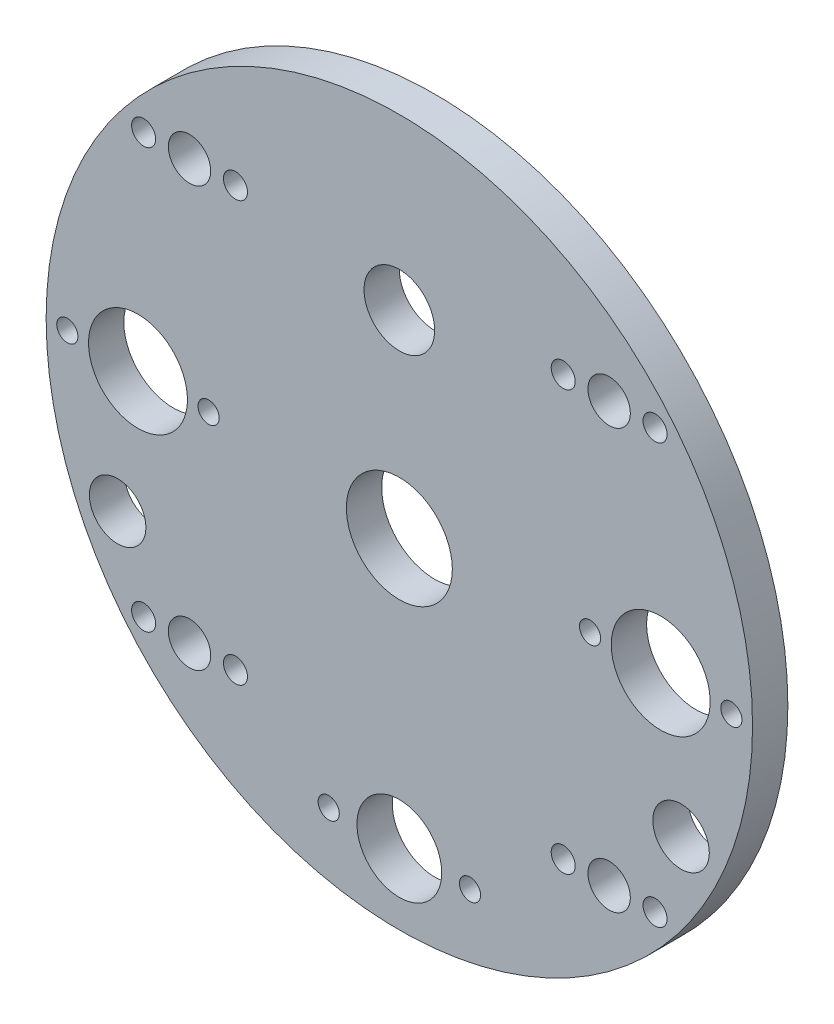
from build123d import *

# Parameters (mm, degrees)
SKETCH1_R                  = 50
BOSS_EXTRUDE1_DEPTH        = 5
F_14_0_14_DIAMETER_HOLE1_D = 14
SKETCH7_R                  = 5
CUT_EXTRUDE1_DEPTH         = 10
SKETCH8_R                  = 3
CUT_EXTRUDE2_DEPTH         = 10
CIRPATTERN1_COUNT          = 4
SKETCH9_R                  = 7.5
CUT_EXTRUDE3_DEPTH         = 10
SKETCH10_R                 = 1.5
SKETCH10_R_2               = 6
CUT_EXTRUDE4_DEPTH         = 10
SKETCH12_R                 = 4
CUT_EXTRUDE5_DEPTH         = 10
M3_CLEARANCE_HOLE1_D       = 3.4
MIRROR3_COPY_1_D           = 3.4


with BuildPart() as part:
    # Sketch1 → Boss-Extrude1 (new body)
    with BuildSketch(Plane.XY):
        Circle(SKETCH1_R)
    extrude(amount=BOSS_EXTRUDE1_DEPTH)

    # Ø14.0 (14) Diameter Hole1 (through all)
    with Locations(Plane(origin=(0, 0, 0), x_dir=(-1, 0, 0), z_dir=(0, 0, -1))):
        with Locations((37, 0), (-37, 0)):
            Hole(F_14_0_14_DIAMETER_HOLE1_D / 2)

    # Sketch7 → Cut-Extrude1 (cut)
    with BuildSketch(Plane.XY.offset(5)):
        with Locations((0, 26)):
            Circle(SKETCH7_R)
    extrude(amount=-CUT_EXTRUDE1_DEPTH, mode=Mode.SUBTRACT)

    # Sketch8 → Cut-Extrude2 (cut)
    with BuildSketch(Plane.XY.offset(5)):
        with Locations((-29.69848481, 29.69848481)):
            Circle(SKETCH8_R)
    cut_extrude2 = extrude(amount=-CUT_EXTRUDE2_DEPTH, mode=Mode.SUBTRACT)

    # CirPattern1: Cut-Extrude2 ×4 about axis
    cirpattern1_axis = Axis((0, 0, 0), (0, 0, 1))
    for i in range(1, CIRPATTERN1_COUNT):
        add(cut_extrude2.rotate(cirpattern1_axis, i * 360 / CIRPATTERN1_COUNT), mode=Mode.SUBTRACT)

    # Sketch9 → Cut-Extrude3 (cut)
    with BuildSketch(Plane.XY.offset(5)):
        with Locations((0, -2)):
            Circle(SKETCH9_R)
    extrude(amount=-CUT_EXTRUDE3_DEPTH, mode=Mode.SUBTRACT)

    # Sketch10 → Cut-Extrude4 (cut)
    with BuildSketch(Plane.XY.offset(5)):
        with Locations((-47, 0)):
            Circle(SKETCH10_R)
        with Locations((-27, 0)):
            Circle(SKETCH10_R)
        with Locations((27, 0)):
            Circle(SKETCH10_R)
        with Locations((47, 0)):
            Circle(SKETCH10_R)
        with Locations((10, -40)):
            Circle(SKETCH10_R)
        with Locations((-10, -40)):
            Circle(SKETCH10_R)
        with Locations((0, -40)):
            Circle(SKETCH10_R_2)
    extrude(amount=-CUT_EXTRUDE4_DEPTH, mode=Mode.SUBTRACT)

    # Sketch12 → Cut-Extrude5 (cut)
    with BuildSketch(Plane.XY.offset(5)):
        with Locations((-39.87754263, -18.595203517)):
            Circle(SKETCH12_R)
    cut_extrude5 = extrude(amount=-CUT_EXTRUDE5_DEPTH, mode=Mode.SUBTRACT)

    # Mirror1: Cut-Extrude5 across plane
    add(cut_extrude5.mirror(Plane(origin=(0, 0, 0), x_dir=(0, 0, 1), z_dir=(1, 0, 0))), mode=Mode.SUBTRACT)

    # M3 Clearance Hole1 (through all)
    with Locations(Plane.XY.offset(5)):
        with Locations((-36.19848481, -29.69848481), (-23.19848481, -29.69848481)):
            m3_clearance_hole1 = Hole(M3_CLEARANCE_HOLE1_D / 2)

    # Mirror2: M3 Clearance Hole1 across plane
    add(m3_clearance_hole1.mirror(Plane.ZX), mode=Mode.SUBTRACT)

    # Mirror3: M3 Clearance Hole1 across plane
    add(m3_clearance_hole1.mirror(Plane(origin=(0, 0, 0), x_dir=(0, 0, 1), z_dir=(1, 0, 0))), mode=Mode.SUBTRACT)

    # Mirror3 copy 1 (through all)
    with Locations(Plane(origin=(0, 0, 5), x_dir=(-1, 0, 0), z_dir=(0, 0, 1))):
        with Locations((-36.19848481, -29.69848481), (-23.19848481, -29.69848481)):
            Hole(MIRROR3_COPY_1_D / 2)


solid = part.part
